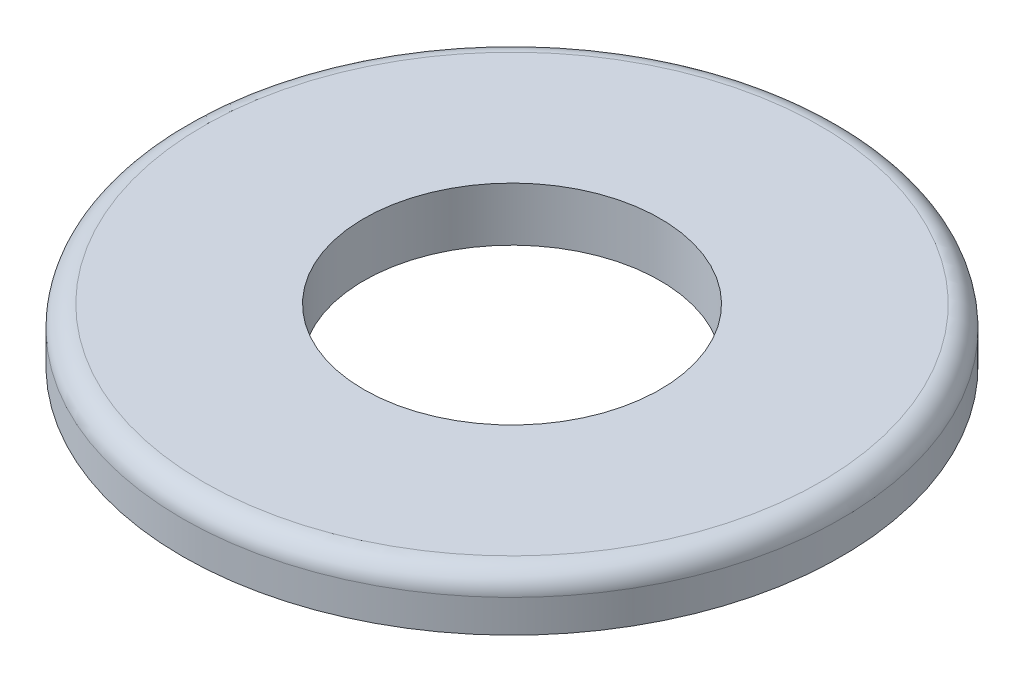
from build123d import *

# Parameters (mm, degrees)
SKETCH3_R                = 7.9375
SKETCH3_R_2              = 3.5687
BOSS_EXTRUDE1_DEPTH      = 0.6477
BOSS_EXTRUDE1_DEPTH_BACK = 0.6477
FILLET1_R                = 0.508


with BuildPart() as part:
    # Sketch3 → Boss-Extrude1 (new body, two sides)
    with BuildSketch(Plane(origin=(0, 0, 0), x_dir=(1, 0, 0), z_dir=(0, 1, 0))) as boss_extrude1_sk:
        Circle(SKETCH3_R)
        Circle(SKETCH3_R_2, mode=Mode.SUBTRACT)
    extrude(amount=BOSS_EXTRUDE1_DEPTH)
    extrude(boss_extrude1_sk.sketch, amount=-BOSS_EXTRUDE1_DEPTH_BACK)

    # Fillet1
    fillet1_edges = [part.edges().sort_by_distance(p)[0] for p in [
        (-7.9375, 0.6477, 0),
    ]]
    fillet(fillet1_edges, radius=FILLET1_R)


solid = part.part
